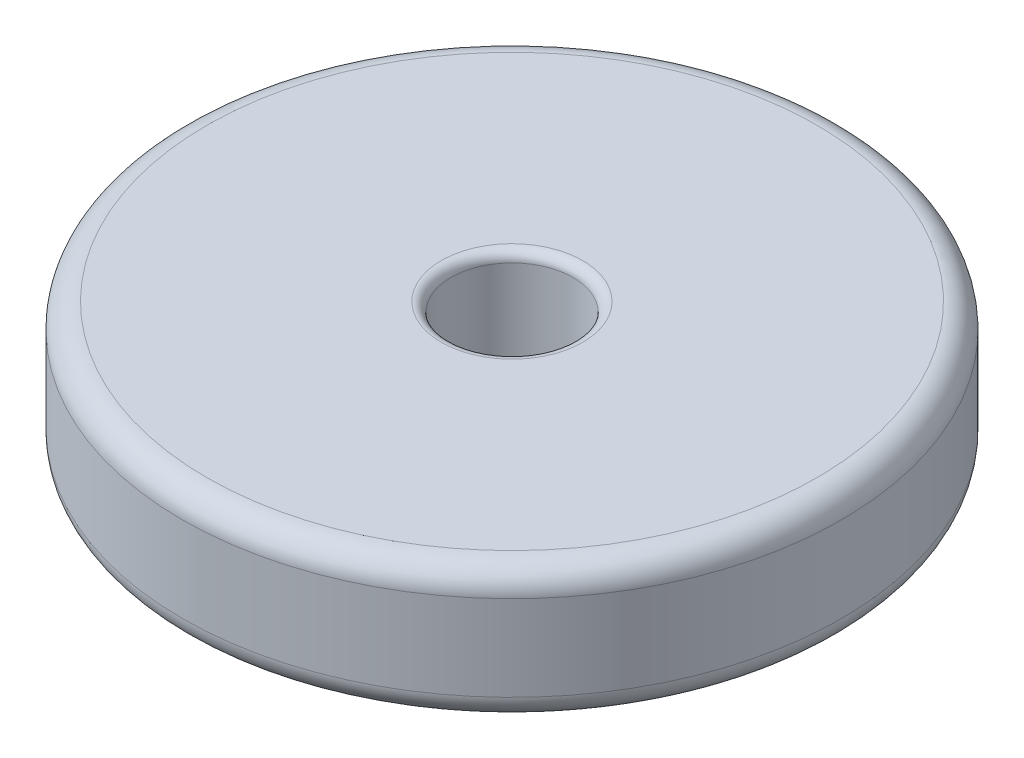
from build123d import *

# Parameters (mm, degrees)
SKETCH1_R           = 85.725
SKETCH1_R_2         = 15.875
BOSS_EXTRUDE1_DEPTH = 34.925
FILLET1_R           = 6.35
FILLET2_R           = 2.54


with BuildPart() as part:
    # Sketch1 → Boss-Extrude1 (new body)
    with BuildSketch(Plane(origin=(0, 0, 0), x_dir=(1, 0, 0), z_dir=(0, 1, 0))):
        Circle(SKETCH1_R)
        Circle(SKETCH1_R_2, mode=Mode.SUBTRACT)
    extrude(amount=BOSS_EXTRUDE1_DEPTH)

    # Fillet1
    fillet1_edges = [part.edges().sort_by_distance(p)[0] for p in [
        (-85.725, 0, 0),
        (-85.725, 34.925, 0),
    ]]
    fillet(fillet1_edges, radius=FILLET1_R)

    # Fillet2
    fillet2_edges = [part.edges().sort_by_distance(p)[0] for p in [
        (-15.875, 0, 0),
        (-15.875, 34.925, 0),
    ]]
    fillet(fillet2_edges, radius=FILLET2_R)


solid = part.part
